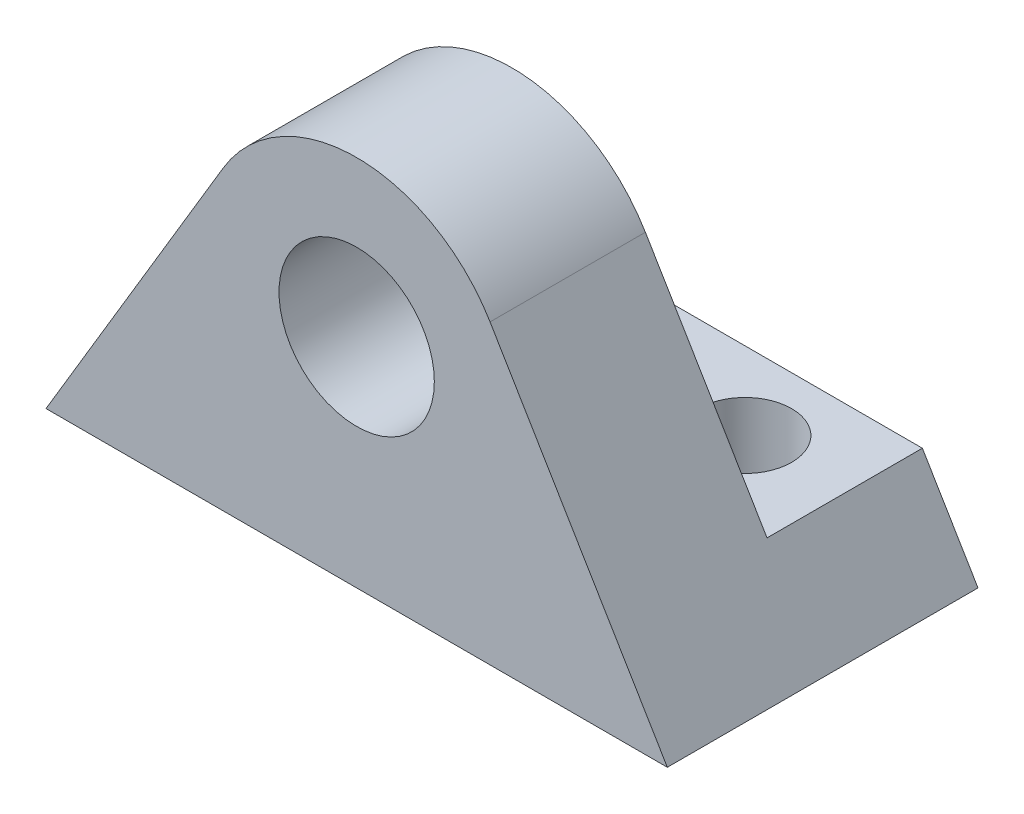
from build123d import *

# Parameters (mm, degrees)
SKETCH2_R           = 3.175
BOSS_EXTRUDE2_DEPTH = 6.35
SKETCH6_W           = 20.852651852
SKETCH6_H           = 11.43
CUT_EXTRUDE3_DEPTH  = 6.35
SKETCH7_R           = 1.905
CUT_EXTRUDE4_DEPTH  = 6.35


with BuildPart() as part:
    # Sketch2 → Boss-Extrude2 (new body, symmetric)
    with BuildSketch(Plane.XY):
        with BuildLine():
            Line((0, 0), (25.4, 0))
            Line((25.4, 0), (18.152847328, 12.144067611))
            ThreePointArc((18.152847328, 12.144067611), (12.7, 15.24), (7.247152672, 12.144067611))
            Line((7.247152672, 12.144067611), (0, 0))
        make_face()
        with Locations((12.7, 8.89)):
            Circle(SKETCH2_R, mode=Mode.SUBTRACT)
    extrude(amount=BOSS_EXTRUDE2_DEPTH, both=True)

    # Sketch6 → Cut-Extrude3 (cut)
    with BuildSketch(Plane.XY):
        with Locations((12.7, 9.525)):
            Rectangle(SKETCH6_W, SKETCH6_H)
    extrude(amount=-CUT_EXTRUDE3_DEPTH, mode=Mode.SUBTRACT)

    # Sketch7 → Cut-Extrude4 (cut)
    with BuildSketch(Plane(origin=(0, 3.81, 0), x_dir=(1, 0, 0), z_dir=(0, 1, 0))):
        with Locations((6.35, 3.175)):
            Circle(SKETCH7_R)
        with Locations((19.05, 3.175)):
            Circle(SKETCH7_R)
    extrude(amount=-CUT_EXTRUDE4_DEPTH, mode=Mode.SUBTRACT)


solid = part.part
